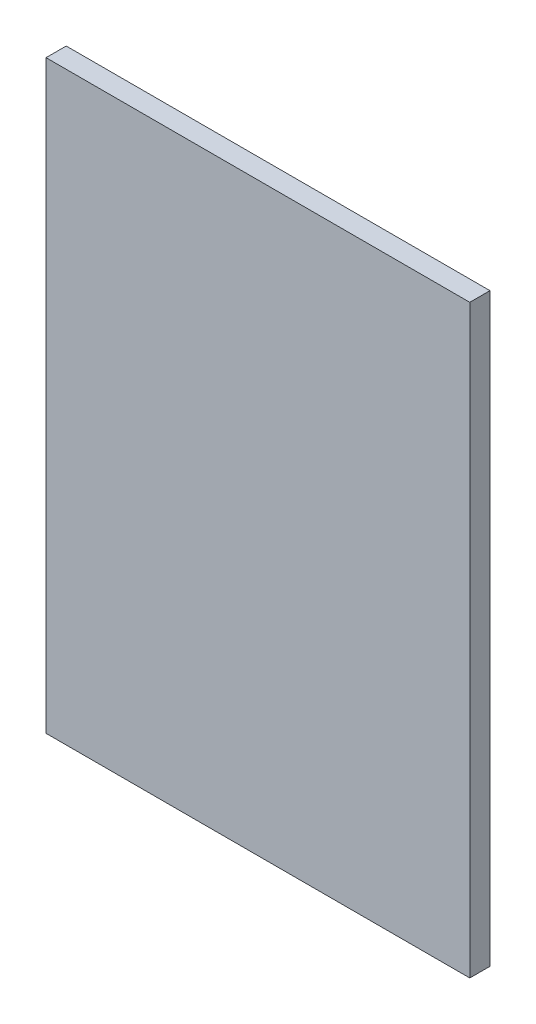
from build123d import *

# Parameters (mm, degrees)
SKETCH1_W           = 42
SKETCH1_H           = 58
BOSS_EXTRUDE1_DEPTH = 2


with BuildPart() as part:
    # Sketch1 → Boss-Extrude1 (new body)
    with BuildSketch(Plane.XY):
        with Locations((-2.449035813, -14.32231405)):
            Rectangle(SKETCH1_W, SKETCH1_H)
    extrude(amount=-BOSS_EXTRUDE1_DEPTH)


solid = part.part
